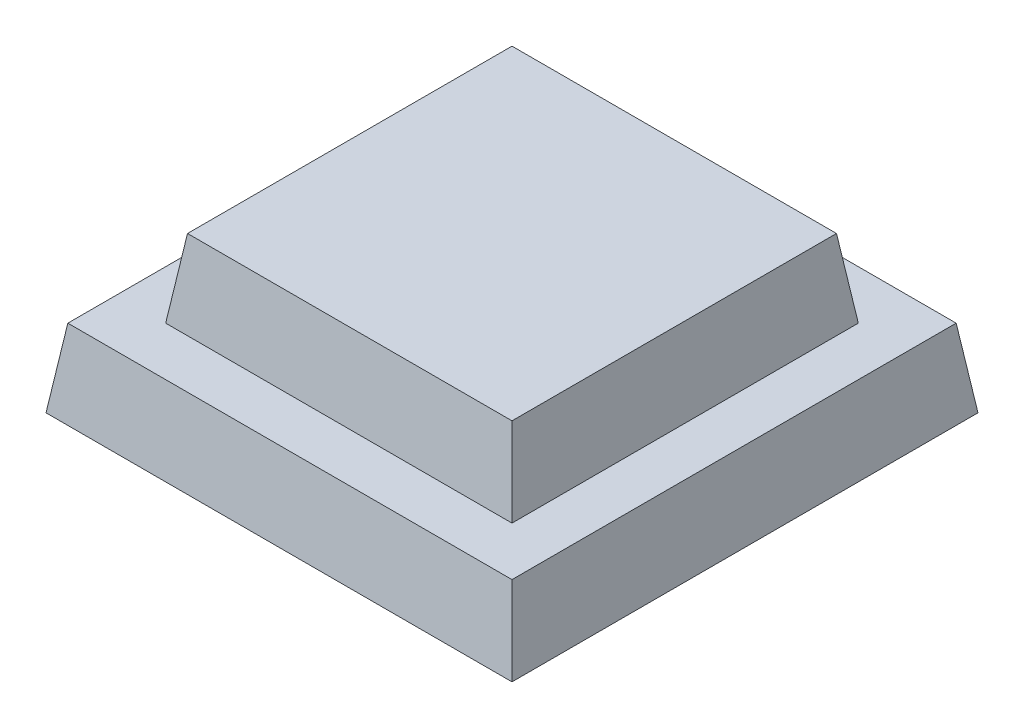
from build123d import *

# Parameters (mm, degrees)
SKETCH2_W           = 19.05
SKETCH2_H           = 19.05
BOSS_EXTRUDE1_DEPTH = 3.175
BOSS_EXTRUDE1_TAPER = 8
SKETCH3_W           = 14.1575657
SKETCH3_H           = 14.1575657
BOSS_EXTRUDE2_DEPTH = 3.175
BOSS_EXTRUDE2_TAPER = 8


with BuildPart() as part:
    # Sketch2 → Boss-Extrude1 (new body)
    with BuildSketch(Plane(origin=(0, 0, 0), x_dir=(1, 0, 0), z_dir=(0, 1, 0))):
        Rectangle(SKETCH2_W, SKETCH2_H)
    extrude(amount=BOSS_EXTRUDE1_DEPTH, taper=BOSS_EXTRUDE1_TAPER)

    # Sketch3 → Boss-Extrude2 (add)
    with BuildSketch(Plane(origin=(0, 3.175, 0), x_dir=(1, 0, 0), z_dir=(0, 1, 0))):
        Rectangle(SKETCH3_W, SKETCH3_H)
    extrude(amount=BOSS_EXTRUDE2_DEPTH, taper=BOSS_EXTRUDE2_TAPER)


solid = part.part
